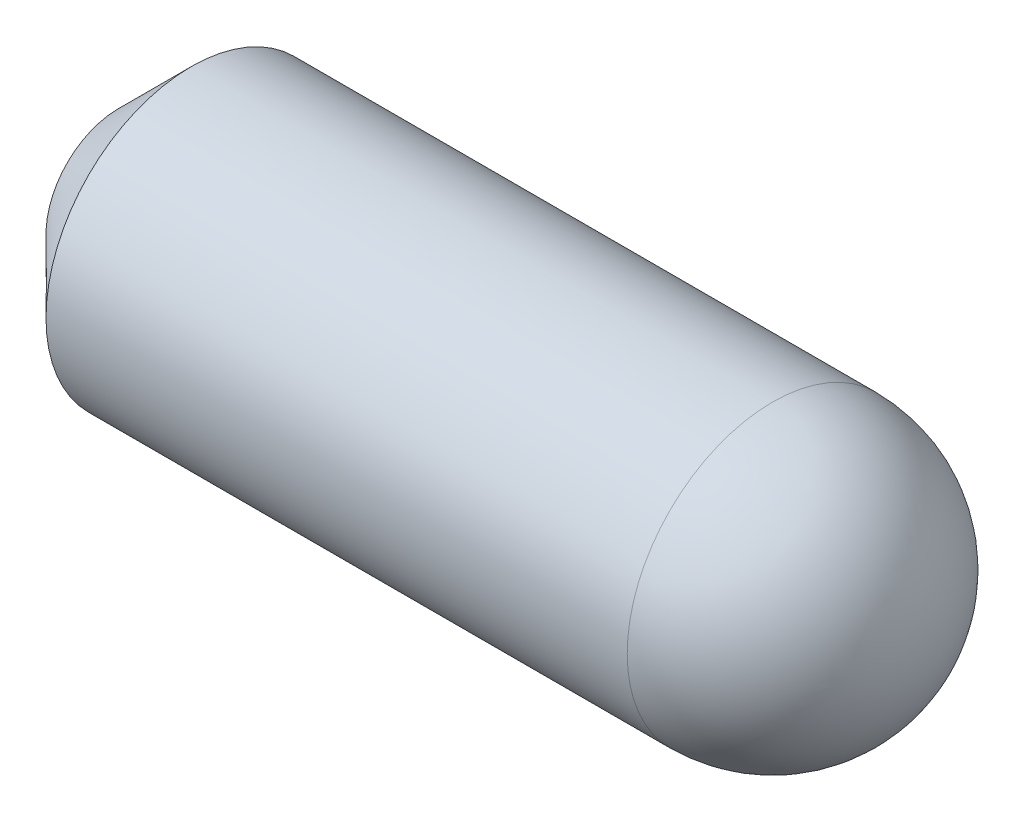
from build123d import *

# Parameters (mm, degrees)
SKETCH1_W     = 11
SKETCH1_H     = 2
CHAMFER1_SIZE = 1
FILLET1_R     = 2


with BuildPart() as part:
    # Sketch1 → Revolve1 (revolve)
    with BuildSketch(Plane.XY):
        with Locations((5.5, 1)):
            Rectangle(SKETCH1_W, SKETCH1_H)
    revolve(axis=Axis((-4.801500481, 0, 0), (1, 0, 0)))

    # Chamfer1
    chamfer1_edges = [part.edges().sort_by_distance(p)[0] for p in [
        (0, -2, 0),
    ]]
    chamfer(chamfer1_edges, length=CHAMFER1_SIZE)

    # Fillet1
    fillet1_edges = [part.edges().sort_by_distance(p)[0] for p in [
        (11, -2, 0),
    ]]
    fillet(fillet1_edges, radius=FILLET1_R)


solid = part.part
